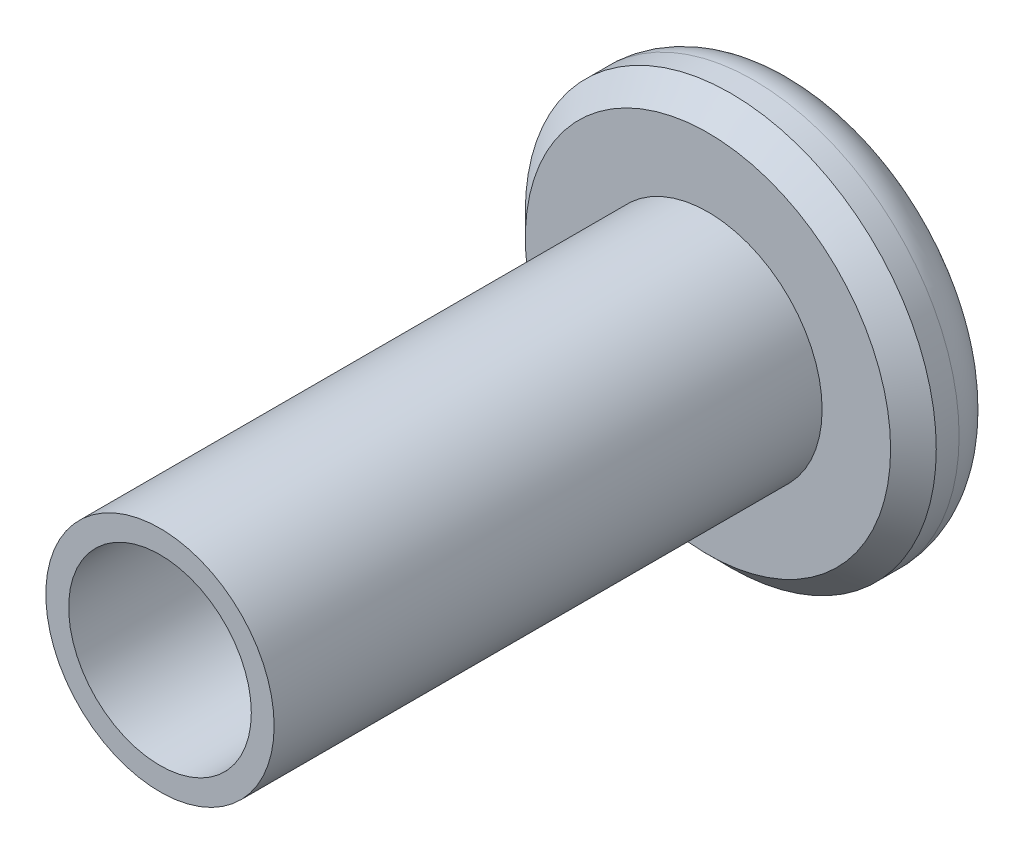
from build123d import *

# Parameters (mm, degrees)
SKETCH_1_R          = 4.5
EXTRUDE_1_DEPTH     = 2
SKETCH_2_R          = 2.5
SKETCH_2_R_2        = 2
EXTRUDE_2_DEPTH     = 12
FILLET_1_R          = 1
CHAMFER_1_SIZE      = 0.5
CUT_EXTRUDE_1_DEPTH = 1


with BuildPart() as part:
    # 草图1 → 凸台-拉伸1 (new body)
    with BuildSketch(Plane.XY):
        Circle(SKETCH_1_R)
    extrude(amount=EXTRUDE_1_DEPTH)

    # 草图2 → 凸台-拉伸2 (add)
    with BuildSketch(Plane.XY.offset(2)):
        Circle(SKETCH_2_R)
        Circle(SKETCH_2_R_2, mode=Mode.SUBTRACT)
    extrude(amount=EXTRUDE_2_DEPTH)

    # 圆角1
    fillet_1_edges = [part.edges().sort_by_distance(p)[0] for p in [
        (-4.5, 0, 0),
    ]]
    fillet(fillet_1_edges, radius=FILLET_1_R)

    # 倒角1
    chamfer_1_edges = [part.edges().sort_by_distance(p)[0] for p in [
        (-4.5, 0, 2),
    ]]
    chamfer(chamfer_1_edges, length=CHAMFER_1_SIZE)

    # 草图3 → 切除-拉伸1 (cut)
    with BuildSketch(Plane(origin=(0, 0, 0), x_dir=(-1, 0, 0), z_dir=(0, 0, -1))):
        Polygon((0.866025404, -1.5), (1.732050808, 0), (0.866025404, 1.5), (-0.866025404, 1.5), (-1.732050808, 0), (-0.866025404, -1.5), align=None)
    extrude(amount=-CUT_EXTRUDE_1_DEPTH, mode=Mode.SUBTRACT)


solid = part.part
